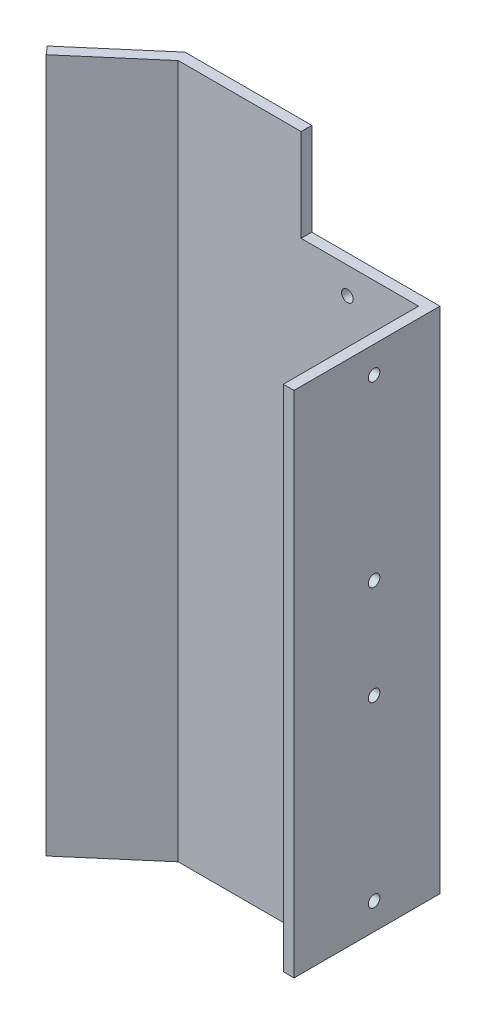
from build123d import *

# Parameters (mm, degrees)
SALIENTE_EXTRUIR1_DEPTH    = 143
CORTAR_EXTRUIR1_REACH      = 91.714
CROQUIS2_R                 = 1.625
CORTAR_EXTRUIR2_REACH      = 38.5
CROQUIS3_R                 = 1.625
CROQUIS4_W                 = 7.355559709
CROQUIS4_H                 = 144.434060974
CORTAR_EXTRUIR3_DEPTH      = 30
SALIENTE_EXTRUIR2_DEPTH    = 1
CROQUIS6_W                 = 1
CROQUIS6_H                 = 143
SALIENTE_EXTRUIR3_DEPTH    = 3.5
SALIENTE_EXTRUIR4_DEPTH    = 26
SALIENTE_EXTRUIR5_DEPTH    = 26
SALIENTE_EXTRUIR6_DEPTH    = 195
CROQUIS10_R                = 1.625
SALIENTE_EXTRUIR7_DEPTH    = 2
CORTAR_EXTRUIR4_DEPTH      = 1
CORTAR_EXTRUIR4_DEPTH_BACK = 196
CROQUIS12_W                = 41
CROQUIS12_H                = 143
CROQUIS12_R                = 1.625
SALIENTE_EXTRUIR8_DEPTH    = 2


with BuildPart() as part:
    # Croquis1 → Saliente-Extruir1 (new body)
    with BuildSketch(Plane(origin=(0, 0, 0), x_dir=(1, 0, 0), z_dir=(0, 1, 0))):
        Polygon((0, 0), (18, 0), (18, 36.5), (-53.969911232, 36.5), (-71.714014286, 21.29146431), (-71.063240069, 20.532193003), (-53.6, 35.5), (17, 35.5), (17, 1), (0, 1), align=None)
    extrude(amount=SALIENTE_EXTRUIR1_DEPTH)

    # Croquis2 → Cortar-Extruir1 (cut, up to next)
    with BuildSketch(Plane(origin=(18, 0, 0), x_dir=(0, 0, -1), z_dir=(1, 0, 0)), mode=Mode.PRIVATE) as cortar_extruir1_sk1:
        with Locations((20, 135.5)):
            Circle(CROQUIS2_R)
    cortar_extruir1_tool1 = extrude(cortar_extruir1_sk1.sketch, amount=-CORTAR_EXTRUIR1_REACH, mode=Mode.PRIVATE) & part.part
    add(cortar_extruir1_tool1.solids().sort_by_distance((18, 135.5, -20))[0], mode=Mode.SUBTRACT)
    # Croquis2 → Cortar-Extruir1 (cut, up to next)
    with BuildSketch(Plane(origin=(18, 0, 0), x_dir=(0, 0, -1), z_dir=(1, 0, 0)), mode=Mode.PRIVATE) as cortar_extruir1_sk2:
        with Locations((20, 7.5)):
            Circle(CROQUIS2_R)
    cortar_extruir1_tool2 = extrude(cortar_extruir1_sk2.sketch, amount=-CORTAR_EXTRUIR1_REACH, mode=Mode.PRIVATE) & part.part
    add(cortar_extruir1_tool2.solids().sort_by_distance((18, 7.5, -20))[0], mode=Mode.SUBTRACT)
    # Croquis2 → Cortar-Extruir1 (cut, up to next)
    with BuildSketch(Plane(origin=(18, 0, 0), x_dir=(0, 0, -1), z_dir=(1, 0, 0)), mode=Mode.PRIVATE) as cortar_extruir1_sk3:
        with Locations((20, 85.5)):
            Circle(CROQUIS2_R)
    cortar_extruir1_tool3 = extrude(cortar_extruir1_sk3.sketch, amount=-CORTAR_EXTRUIR1_REACH, mode=Mode.PRIVATE) & part.part
    add(cortar_extruir1_tool3.solids().sort_by_distance((18, 85.5, -20))[0], mode=Mode.SUBTRACT)
    # Croquis2 → Cortar-Extruir1 (cut, up to next)
    with BuildSketch(Plane(origin=(18, 0, 0), x_dir=(0, 0, -1), z_dir=(1, 0, 0)), mode=Mode.PRIVATE) as cortar_extruir1_sk4:
        with Locations((20, 57.5)):
            Circle(CROQUIS2_R)
    cortar_extruir1_tool4 = extrude(cortar_extruir1_sk4.sketch, amount=-CORTAR_EXTRUIR1_REACH, mode=Mode.PRIVATE) & part.part
    add(cortar_extruir1_tool4.solids().sort_by_distance((18, 57.5, -20))[0], mode=Mode.SUBTRACT)

    # Croquis3 → Cortar-Extruir2 (cut, up to next)
    with BuildSketch(Plane(origin=(0, 0, -36.5), x_dir=(-1, 0, 0), z_dir=(0, 0, -1)), mode=Mode.PRIVATE) as cortar_extruir2_sk1:
        with Locations((3, 7.5)):
            Circle(CROQUIS3_R)
    cortar_extruir2_tool1 = extrude(cortar_extruir2_sk1.sketch, amount=-CORTAR_EXTRUIR2_REACH, mode=Mode.PRIVATE) & part.part
    add(cortar_extruir2_tool1.solids().sort_by_distance((-3, 7.5, -36.5))[0], mode=Mode.SUBTRACT)
    # Croquis3 → Cortar-Extruir2 (cut, up to next)
    with BuildSketch(Plane(origin=(0, 0, -36.5), x_dir=(-1, 0, 0), z_dir=(0, 0, -1)), mode=Mode.PRIVATE) as cortar_extruir2_sk2:
        with Locations((3, 135.5)):
            Circle(CROQUIS3_R)
    cortar_extruir2_tool2 = extrude(cortar_extruir2_sk2.sketch, amount=-CORTAR_EXTRUIR2_REACH, mode=Mode.PRIVATE) & part.part
    add(cortar_extruir2_tool2.solids().sort_by_distance((-3, 135.5, -36.5))[0], mode=Mode.SUBTRACT)
    # Croquis3 → Cortar-Extruir2 (cut, up to next)
    with BuildSketch(Plane(origin=(0, 0, -36.5), x_dir=(-1, 0, 0), z_dir=(0, 0, -1)), mode=Mode.PRIVATE) as cortar_extruir2_sk3:
        with Locations((3, 57.5)):
            Circle(CROQUIS3_R)
    cortar_extruir2_tool3 = extrude(cortar_extruir2_sk3.sketch, amount=-CORTAR_EXTRUIR2_REACH, mode=Mode.PRIVATE) & part.part
    add(cortar_extruir2_tool3.solids().sort_by_distance((-3, 57.5, -36.5))[0], mode=Mode.SUBTRACT)
    # Croquis3 → Cortar-Extruir2 (cut, up to next)
    with BuildSketch(Plane(origin=(0, 0, -36.5), x_dir=(-1, 0, 0), z_dir=(0, 0, -1)), mode=Mode.PRIVATE) as cortar_extruir2_sk4:
        with Locations((3, 85.5)):
            Circle(CROQUIS3_R)
    cortar_extruir2_tool4 = extrude(cortar_extruir2_sk4.sketch, amount=-CORTAR_EXTRUIR2_REACH, mode=Mode.PRIVATE) & part.part
    add(cortar_extruir2_tool4.solids().sort_by_distance((-3, 85.5, -36.5))[0], mode=Mode.SUBTRACT)

    # Croquis4 → Cortar-Extruir3 (cut)
    with BuildSketch(Plane(origin=(18, 0, 0), x_dir=(0, 0, -1), z_dir=(1, 0, 0))):
        with Locations((-2.677779855, 72.217030487)):
            Rectangle(CROQUIS4_W, CROQUIS4_H)
    extrude(amount=-CORTAR_EXTRUIR3_DEPTH, mode=Mode.SUBTRACT)

    # Croquis5 → Saliente-Extruir2 (add)
    with BuildSketch(Plane(origin=(-40.891807576, 0, -47.709290524), x_dir=(-0.759271307, 0, 0.650774217), z_dir=(-0.650774217, 0, -0.759271307))):
        Polygon((17.224546128, 0), (35.59445736, -26), (40.59445736, -26), (40.59445736, 0), (17.59445736, 0), align=None)
        Polygon((40.59445736, 143), (17.59445736, 143), (17.224546128, 143), (35.59445736, 169), (40.59445736, 169), align=None)
    extrude(amount=-SALIENTE_EXTRUIR2_DEPTH)

    # Croquis6 → Saliente-Extruir3 (add)
    with BuildSketch(Plane.XY.offset(-1)):
        with Locations((17.5, 71.5)):
            Rectangle(CROQUIS6_W, CROQUIS6_H)
    extrude(amount=SALIENTE_EXTRUIR3_DEPTH)

    # Croquis7 → Saliente-Extruir4 (add)
    with BuildSketch(Plane.XZ.offset(26)):
        Polygon((-67.266883532, -23.786064089), (-67.917657749, -24.545335397), (-53.972777222, -36.497543549), (-53.969911232, -36.5), (-16, -36.5), (-16, -35.5), (-53.6, -35.5), align=None)
    extrude(amount=-SALIENTE_EXTRUIR4_DEPTH)

    # Croquis8 → Saliente-Extruir5 (add)
    with BuildSketch(Plane(origin=(0, 169, 0), x_dir=(1, 0, 0), z_dir=(0, 1, 0))):
        Polygon((-67.917657749, 24.545335397), (-53.969911232, 36.5), (-16, 36.5), (-16, 35.5), (-53.595402654, 35.5), (-67.264936524, 23.783792475), align=None)
    extrude(amount=-SALIENTE_EXTRUIR5_DEPTH)

    # Croquis9 → Saliente-Extruir6 (add)
    with BuildSketch(Plane(origin=(0, 169, 0), x_dir=(1, 0, 0), z_dir=(0, 1, 0))):
        Polygon((-71.714014286, 21.29146431), (-71.063240069, 20.532193003), (-53.595402654, 35.5), (-50.526737497, 35.5), (-70.520962942, 18.362876171), (-71.822511376, 19.881418786), (-72.473285593, 20.640690093), align=None)
    extrude(amount=-SALIENTE_EXTRUIR6_DEPTH)

    # Croquis10 → Saliente-Extruir7 (add)
    with BuildSketch(Plane(origin=(0, 0, -36.5), x_dir=(-1, 0, 0), z_dir=(0, 0, -1))):
        Polygon((-18, 0), (16, 0), (16, -26), (53.969911232, -26), (53.969911232, 169), (16, 169), (16, 143), (-18, 143), align=None)
        with Locations((3, 7.5)):
            Circle(CROQUIS10_R, mode=Mode.SUBTRACT)
        with Locations((3, 57.5)):
            Circle(CROQUIS10_R, mode=Mode.SUBTRACT)
        with Locations((3, 85.5)):
            Circle(CROQUIS10_R, mode=Mode.SUBTRACT)
        with Locations((3, 135.5)):
            Circle(CROQUIS10_R, mode=Mode.SUBTRACT)
    extrude(amount=SALIENTE_EXTRUIR7_DEPTH)

    # Croquis11 → Cortar-Extruir4 (cut, two sides)
    with BuildSketch(Plane.XZ.offset(26)) as cortar_extruir4_sk:
        Polygon((-53.969911232, -36.5), (-51.636471194, -38.5), (-54.241943892, -38.819087413), align=None)
    extrude(amount=CORTAR_EXTRUIR4_DEPTH, mode=Mode.SUBTRACT)
    extrude(cortar_extruir4_sk.sketch, amount=-CORTAR_EXTRUIR4_DEPTH_BACK, mode=Mode.SUBTRACT)

    # Croquis12 → Saliente-Extruir8 (add)
    with BuildSketch(Plane(origin=(18, 0, 0), x_dir=(0, 0, -1), z_dir=(1, 0, 0))):
        with Locations((18, 71.5)):
            Rectangle(CROQUIS12_W, CROQUIS12_H)
        with Locations((20, 7.5)):
            Circle(CROQUIS12_R, mode=Mode.SUBTRACT)
        with Locations((20, 57.5)):
            Circle(CROQUIS12_R, mode=Mode.SUBTRACT)
        with Locations((20, 85.5)):
            Circle(CROQUIS12_R, mode=Mode.SUBTRACT)
        with Locations((20, 135.5)):
            Circle(CROQUIS12_R, mode=Mode.SUBTRACT)
    extrude(amount=SALIENTE_EXTRUIR8_DEPTH)


solid = part.part
